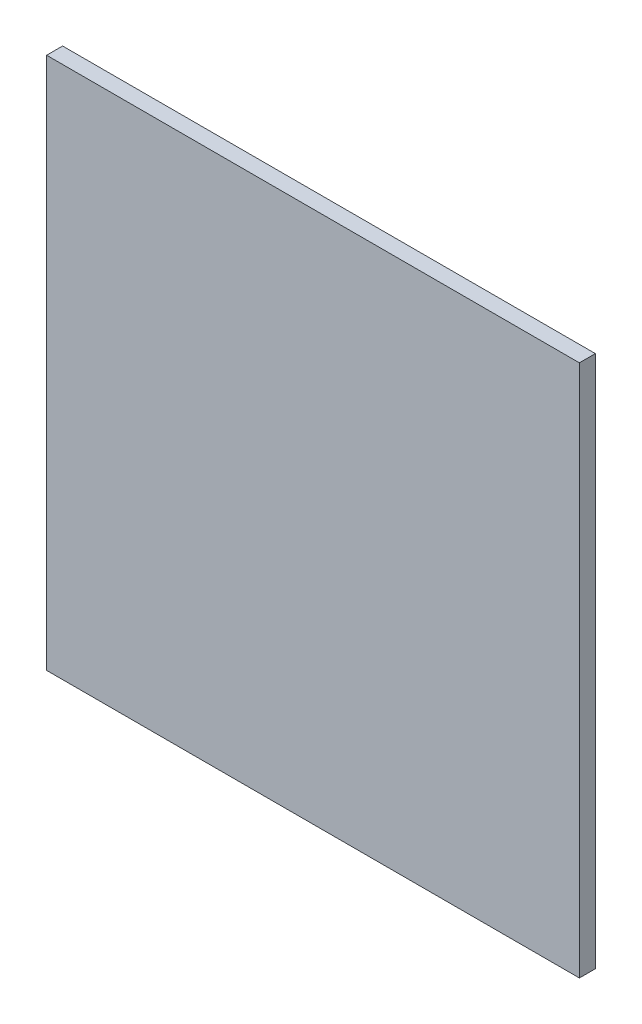
from build123d import *

# Parameters (mm, degrees)
CROQUIS1_W              = 100
CROQUIS1_H              = 100
SALIENTE_EXTRUIR1_DEPTH = 3


with BuildPart() as part:
    # Croquis1 → Saliente-Extruir1 (new body)
    with BuildSketch(Plane.XY):
        with Locations((50, -50)):
            Rectangle(CROQUIS1_W, CROQUIS1_H)
    extrude(amount=SALIENTE_EXTRUIR1_DEPTH)


solid = part.part
